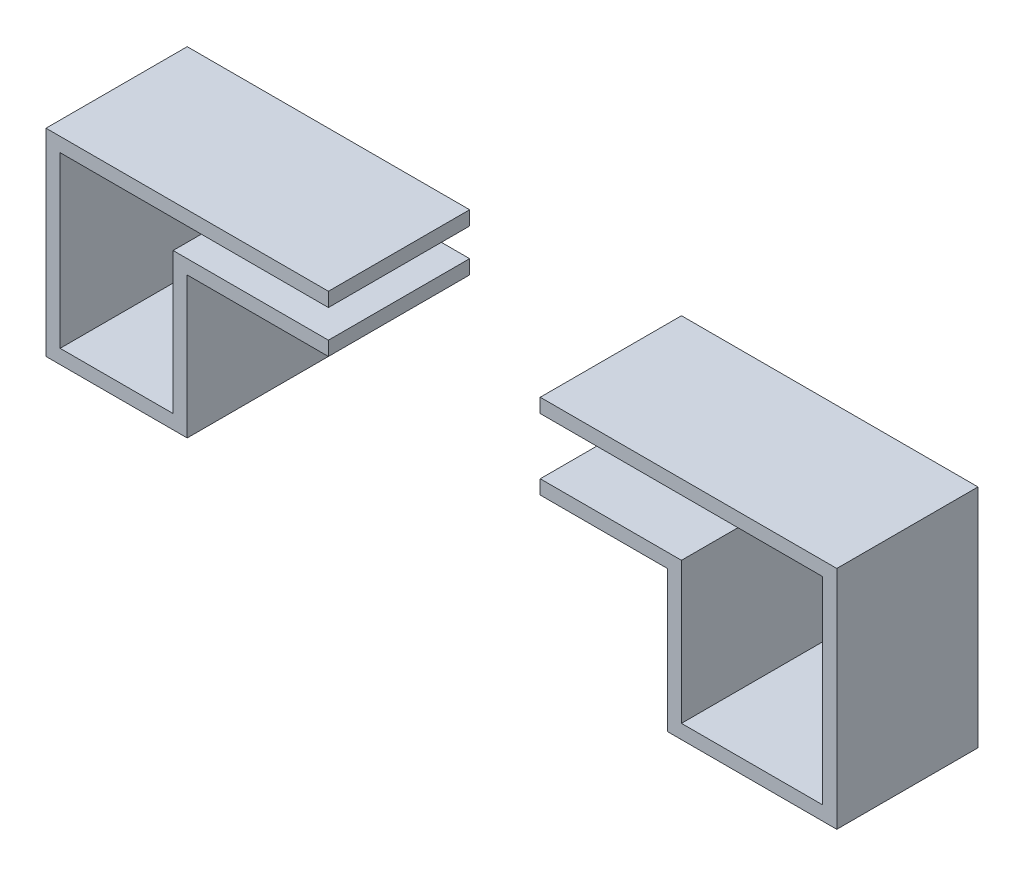
from build123d import *

# Parameters (mm, degrees)
EXTRUDE_THIN2_DEPTH   = 0.5
EXTRUDE_THIN2_2_DEPTH = 0.5


with BuildPart() as part:
    # Sketch2 → Extrude-Thin2 (new body)
    with BuildSketch(Plane.XY):
        Polygon((-0.375, 0.7), (-1.375, 0.7), (-1.375, 0), (-0.875, 0), (-0.875, 0.5), (-0.375, 0.5), (-0.375, 0.55), (-0.925, 0.55), (-0.925, 0.05), (-1.325, 0.05), (-1.325, 0.65), (-0.375, 0.65), align=None)
    extrude(amount=EXTRUDE_THIN2_DEPTH)


with BuildPart() as body_2:
    # Sketch2 → Extrude-Thin2 2 (new body)
    with BuildSketch(Plane.XY):
        Polygon((0.375, 0.7), (1.375, 0.7), (1.375, 0), (0.875, 0), (0.875, 0.5), (0.375, 0.5), (0.375, 0.45), (0.825, 0.45), (0.825, -0.05), (1.425, -0.05), (1.425, 0.75), (0.375, 0.75), align=None)
    extrude(amount=EXTRUDE_THIN2_2_DEPTH)


solid = Compound([part.part, body_2.part])
